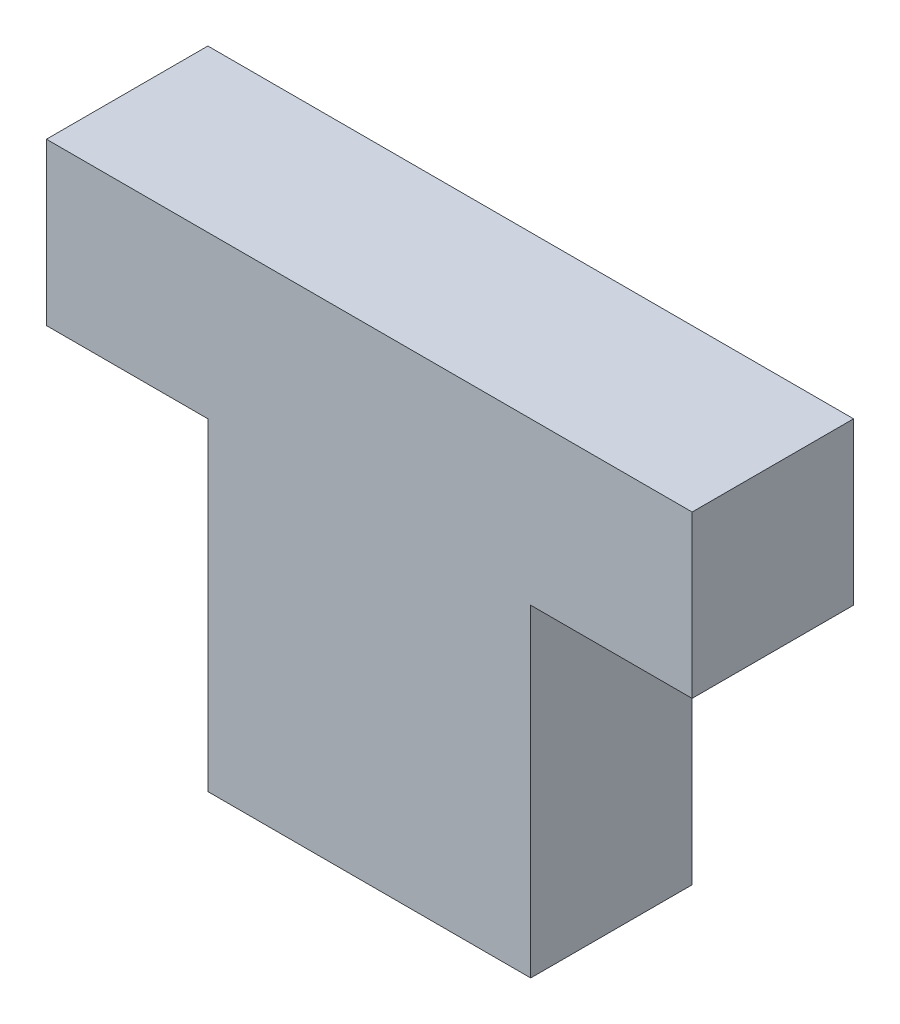
from build123d import *

# Parameters (mm, degrees)
SKETCH1_W           = 10
SKETCH1_H           = 10
BOSS_EXTRUDE1_DEPTH = 5


with BuildPart() as part:
    # Sketch1 → Boss-Extrude1 (new body)
    with BuildSketch(Plane.XY):
        Polygon((-10, 10), (0, 10), (5, 10), (5, 15), (-15, 15), (-15, 10), align=None)
        with Locations((-5, 5)):
            Rectangle(SKETCH1_W, SKETCH1_H)
    extrude(amount=BOSS_EXTRUDE1_DEPTH)


solid = part.part
